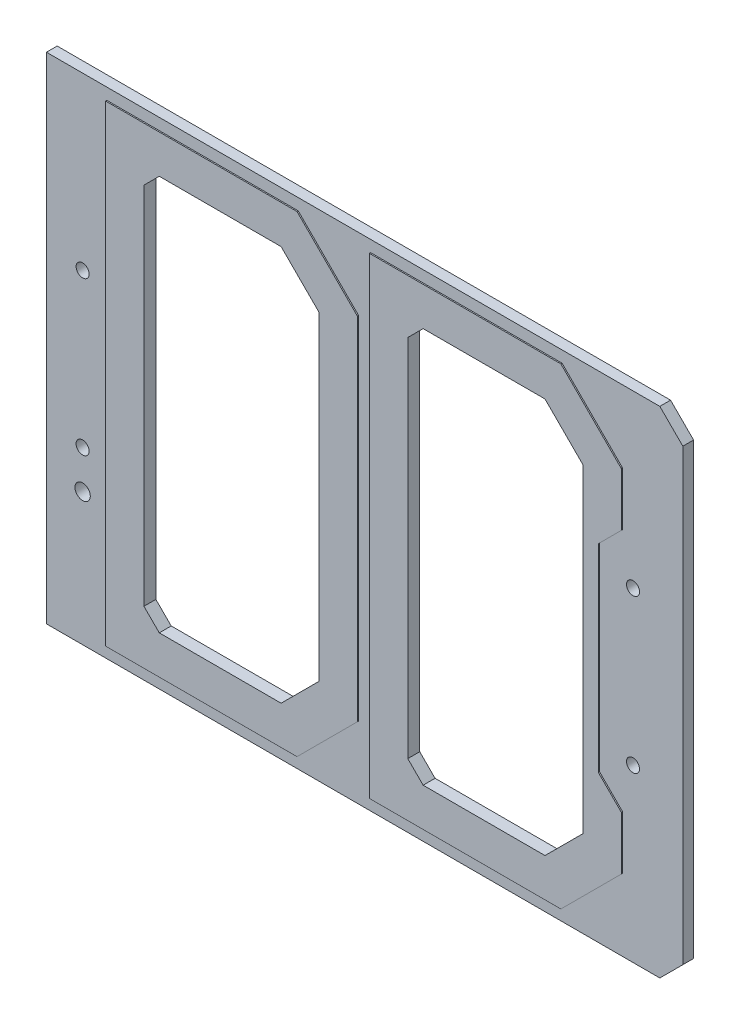
from build123d import *

# Parameters (mm, degrees)
SKETCH1_W           = 105.41
SKETCH1_H           = 82
SKETCH1_R           = 1.0795
SKETCH1_R_2         = 1.27
BOSS_EXTRUDE1_DEPTH = 1.778
BOSS_EXTRUDE2_DEPTH = 0.2
CUT_EXTRUDE1_DEPTH  = 2.978
CHAMFER1_SIZE       = 2.54
CHAMFER2_SIZE       = 3.81


with BuildPart() as part:
    # Sketch1 → Boss-Extrude1 (new body)
    with BuildSketch(Plane.XY):
        Rectangle(SKETCH1_W, SKETCH1_H)
        with Locations((44.45, 12.7)):
            Circle(SKETCH1_R, mode=Mode.SUBTRACT)
        with Locations((44.45, -12.7)):
            Circle(SKETCH1_R, mode=Mode.SUBTRACT)
        with Locations((-46.7106, 12.7)):
            Circle(SKETCH1_R, mode=Mode.SUBTRACT)
        with Locations((-46.7106, -12.7)):
            Circle(SKETCH1_R, mode=Mode.SUBTRACT)
        with Locations((-46.7106, -19.05)):
            Circle(SKETCH1_R_2, mode=Mode.SUBTRACT)
    extrude(amount=BOSS_EXTRUDE1_DEPTH)

    # Sketch2 → Boss-Extrude2 (add)
    with BuildSketch(Plane.XY.offset(1.778)):
        Polygon((-11, 39.095), (-1, 29.095), (-1, -29.095), (-11, -39.095), (-42.705, -39.095), (-42.705, 39.095), align=None)
        Polygon((42.705, 20.205), (38.895, 16.395), (38.895, -16.395), (42.705, -20.205), (42.705, -29.095), (32.705, -39.095), (1, -39.095), (1, 39.095), (32.705, 39.095), (42.705, 29.095), align=None)
    extrude(amount=BOSS_EXTRUDE2_DEPTH)

    # Sketch3 → Cut-Extrude1 (cut, through all)
    with BuildSketch(Plane.XY.offset(1.978)):
        Polygon((-36.355, -32.745), (-36.355, 32.745), (-13.630256121, 32.745), (-7.35, 26.464743879), (-7.35, -26.464743879), (-13.630256121, -32.745), align=None)
        Polygon((7.35, -32.745), (7.35, 32.745), (30.074743879, 32.745), (36.355, 26.464743879), (36.355, -26.464743879), (30.074743879, -32.745), align=None)
    extrude(amount=-CUT_EXTRUDE1_DEPTH, mode=Mode.SUBTRACT)

    # Chamfer1
    chamfer1_edges = [part.edges().sort_by_distance(p)[0] for p in [
        (-36.355, -32.745, 0.989),
        (-36.355, 32.745, 0.989),
        (7.35, -32.745, 0.989),
        (7.35, 32.745, 0.989),
    ]]
    chamfer(chamfer1_edges, length=CHAMFER1_SIZE)

    # Chamfer2
    chamfer2_edges = [part.edges().sort_by_distance(p)[0] for p in [
        (52.705, 41, 0.889),
        (52.705, -41, 0.889),
    ]]
    chamfer(chamfer2_edges, length=CHAMFER2_SIZE)


solid = part.part
